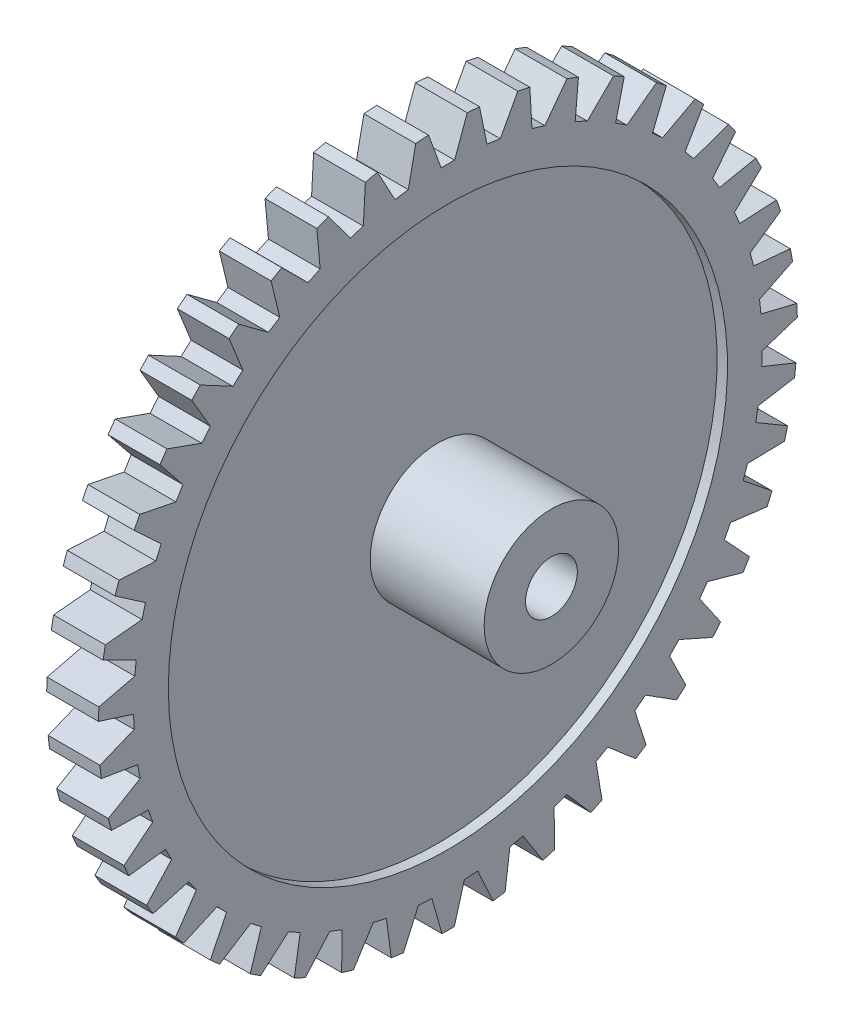
from build123d import *

# Parameters (mm, degrees)
ENL_V_MAT_EXTRU_1_DEPTH      = 1.8
R_P_TITION_CIRCULAIRE1_COUNT = 9
ENL_V_MAT_EXTRU_3_DEPTH      = 10
R_P_TITION_CIRCULAIRE2_COUNT = 43
R_P_TITION_CIRCULAIRE2_ANGLE = 351.54


with BuildPart() as part:
    # Esquisse1 → R_volution1 (revolve)
    with BuildSketch(Plane.XY, mode=Mode.PRIVATE) as r_volution1_sk:
        Polygon((0, 0.5), (4.8, 0.5), (4.8, 1.3), (2.6, 1.3), (2.6, 5.4), (2.8, 5.4), (2.8, 6.75), (1.8, 6.75), (1.8, 1.8), (0, 1.8), align=None)
    revolve(r_volution1_sk.sketch.rotate(Axis((-0.861071576, 0, 0), (1, 0, 0)), 90), axis=Axis((-0.861071576, 0, 0), (1, 0, 0)))  # turned: the seam where the file's is

    # Esquisse2 → Enl_v. mat.-Extru.1 (cut)
    with BuildSketch(Plane.ZY):
        with BuildLine():
            ThreePointArc((0.1, 1.120546742), (0, 1.125), (-0.1, 1.120546742))
            ThreePointArc((-0.1, 1.120546742), (-0.251746652, 1.472784367), (-0.55, 1.71391365))
            ThreePointArc((-0.55, 1.71391365), (0, 1.8), (0.55, 1.71391365))
            ThreePointArc((0.55, 1.71391365), (0.251746652, 1.472784367), (0.1, 1.120546742))
        make_face()
    enl_v_mat_extru_1 = extrude(amount=-ENL_V_MAT_EXTRU_1_DEPTH, mode=Mode.SUBTRACT)

    # R_p_tition circulaire1: Enl_v. mat.-Extru.1 ×9 about axis
    r_p_tition_circulaire1_axis = Axis((0, 0, 0), (1, 0, 0))
    for i in range(1, R_P_TITION_CIRCULAIRE1_COUNT):
        add(enl_v_mat_extru_1.rotate(r_p_tition_circulaire1_axis, i * 360 / R_P_TITION_CIRCULAIRE1_COUNT), mode=Mode.SUBTRACT)

    # Esquisse3 → Enl_v. mat.-Extru.3 (cut)
    with BuildSketch(Plane.ZY.offset(-1.8)):
        Polygon((-0.493970234, 7.07), (-0.13, 6.07), (0.13, 6.07), (0.493970234, 7.07), align=None)
    enl_v_mat_extru_3 = extrude(amount=-ENL_V_MAT_EXTRU_3_DEPTH, mode=Mode.SUBTRACT)

    # R_p_tition circulaire2: Enl_v. mat.-Extru.3 ×43 about axis
    r_p_tition_circulaire2_axis = Axis((0, 0, 0), (-1, 0, 0))
    for i in range(1, R_P_TITION_CIRCULAIRE2_COUNT):
        add(enl_v_mat_extru_3.rotate(r_p_tition_circulaire2_axis, i * R_P_TITION_CIRCULAIRE2_ANGLE / (R_P_TITION_CIRCULAIRE2_COUNT - 1)), mode=Mode.SUBTRACT)


solid = part.part
